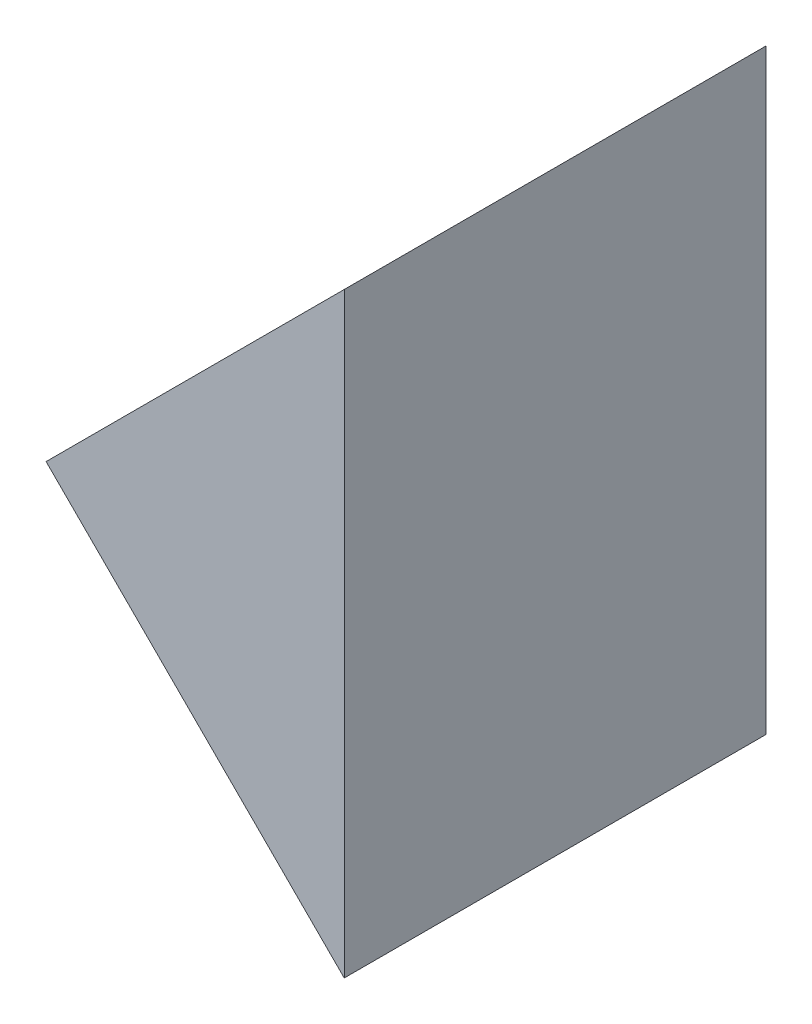
from build123d import *

# Parameters (mm, degrees)
EXTRUDE_1_DEPTH = 10


with BuildPart() as part:
    # 草图1 → 凸台-拉伸1 (new body)
    with BuildSketch(Plane.XY):
        Polygon((110.953339905, 27.551385106), (118.024407717, 34.622452918), (118.024407717, 20.480317294), align=None)
    extrude(amount=EXTRUDE_1_DEPTH)


solid = part.part
